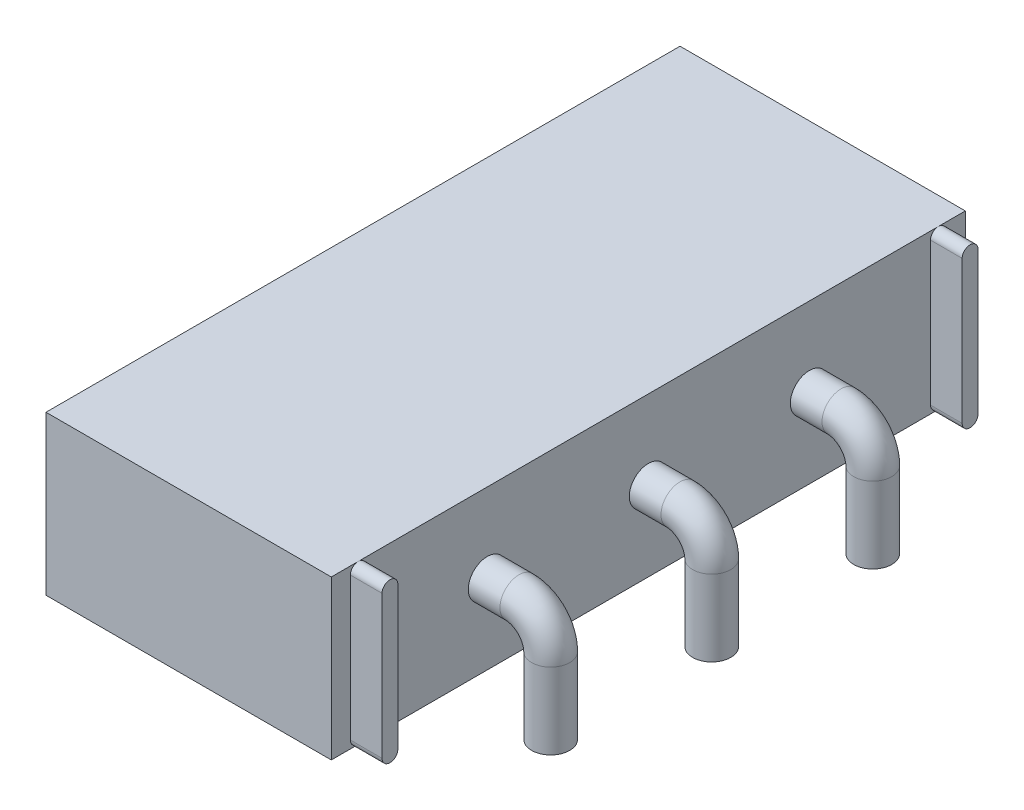
from build123d import *

# Parameters (mm, degrees)
SKETCH1_W          = 4.5
SKETCH1_H          = 10
BODY_SHAPE_DEPTH   = 2.5
SKETCH2_R          = 0.5
OFF_HOLE_DEPTH     = 1
SKETCH3_R          = 0.5
ON_HOLE_DEPTH      = 0.1
BOTTOM_FLAPS_DEPTH = 0.5
SKETCH4_R          = 0.3


with BuildPart() as part:
    # Sketch1 → Body Shape (new body)
    with BuildSketch(Plane(origin=(0, 0, 0), x_dir=(1, 0, 0), z_dir=(0, 1, 0))):
        with Locations((2.25, 5)):
            Rectangle(SKETCH1_W, SKETCH1_H)
    extrude(amount=BODY_SHAPE_DEPTH)

    # Sketch2 → Off Hole (cut)
    with BuildSketch(Plane.ZY):
        with Locations((-9.35, 1.25)):
            Circle(SKETCH2_R)
    extrude(amount=-OFF_HOLE_DEPTH, mode=Mode.SUBTRACT)

    # Sketch3 → On hole (cut)
    with BuildSketch(Plane.ZY):
        with Locations((-0.65, 1.25)):
            Circle(SKETCH3_R)
    extrude(amount=-ON_HOLE_DEPTH, mode=Mode.SUBTRACT)

    # Sketch8 → bottom flaps (add)
    with BuildSketch(Plane(origin=(4.5, 0, 0), x_dir=(0, 0, -1), z_dir=(1, 0, 0))):
        with BuildLine():
            Line((9.7, 0.123206048), (9.7, 2.376793952))
            ThreePointArc((9.7, 2.376793952), (9.575, 2.5), (9.45, 2.376793952))
            Line((9.45, 2.376793952), (9.45, 0.123206048))
            ThreePointArc((9.45, 0.123206048), (9.575, 0), (9.7, 0.123206048))
        make_face()
        with BuildLine():
            Line((0.3, 0.123206048), (0.3, 2.376793952))
            ThreePointArc((0.3, 2.376793952), (0.425, 2.5), (0.55, 2.376793952))
            Line((0.55, 2.376793952), (0.55, 0.123206048))
            ThreePointArc((0.55, 0.123206048), (0.425, 0), (0.3, 0.123206048))
        make_face()
    extrude(amount=BOTTOM_FLAPS_DEPTH)

    # pins: sweep along a path in Sketch9
    with BuildLine(Plane.XY.offset(-7.54)) as pins_path:
        Line((4.5, 1.25), (5, 1.25))
        ThreePointArc((5, 1.25), (5.353553391, 1.103553391), (5.5, 0.75))
        Line((5.5, 0.75), (5.5, -0.45))
    # Sketch4 → pins (sweep)
    with BuildSketch(Plane(origin=(4.5, 0, 0), x_dir=(0, 0, -1), z_dir=(1, 0, 0))):
        with Locations((7.54, 1.25)):
            Circle(SKETCH4_R)
        with Locations((5, 1.25)):
            Circle(SKETCH4_R)
        with Locations((2.46, 1.25)):
            Circle(SKETCH4_R)
    sweep(path=pins_path.line)


solid = part.part
